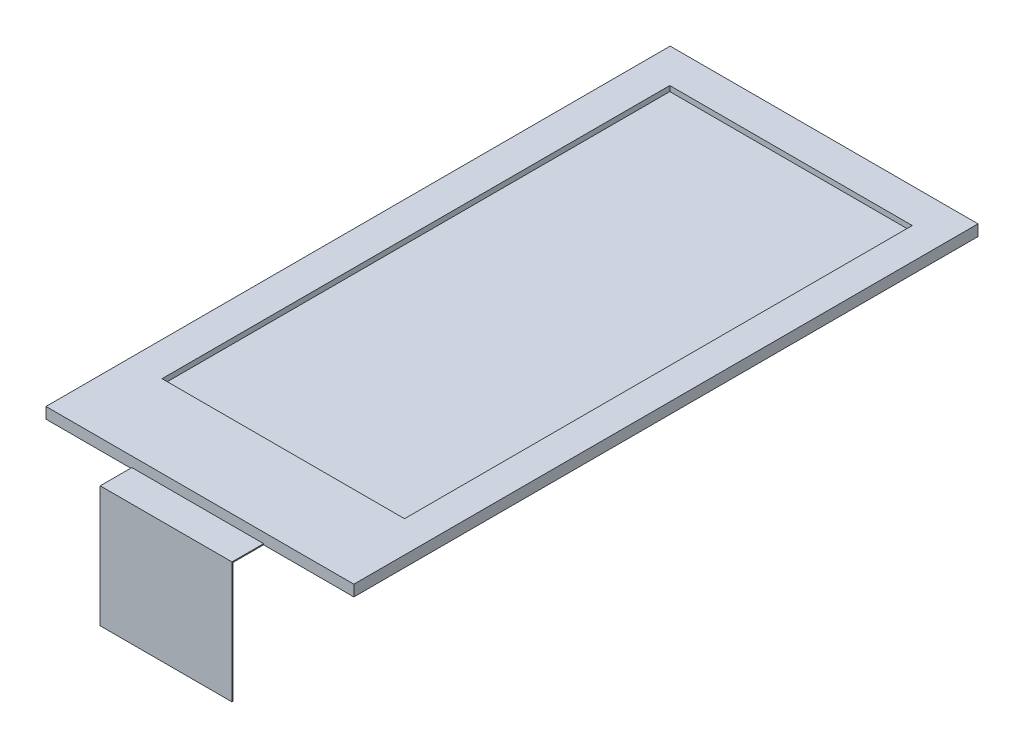
from build123d import *

# Parameters (mm, degrees)
BOSS_EXTRUDE1_DEPTH = 1.5
SKETCH2_W           = 29.2
SKETCH2_H           = 59.2
BOSS_EXTRUDE2_DEPTH = 1.05
SKETCH3_W           = 12.5
SKETCH3_H           = 14.3
BOSS_EXTRUDE3_DEPTH = 0.1
SKETCH4_W           = 12.5
SKETCH4_H           = 3.5
BOSS_EXTRUDE4_DEPTH = 0.2
SKETCH5_W           = 12.5
SKETCH5_H           = 11.4
BOSS_EXTRUDE5_DEPTH = 0.1
SKETCH6_W           = 12.5
SKETCH6_H           = 0.3
CUT_EXTRUDE1_DEPTH  = 11.3
CUT_EXTRUDE2_DEPTH  = 1.5
SKETCH10_W          = 23.000919901
SKETCH10_H          = 48.161967413
CUT_EXTRUDE3_DEPTH  = 0.5


with BuildPart() as part:
    # Sketch1 → Boss-Extrude1 (new body)
    with BuildSketch(Plane(origin=(0, 0, 0), x_dir=(1, 0, 0), z_dir=(0, 1, 0))):
        with BuildLine():
            Line((3.25, 0), (26.95, 0))
            ThreePointArc((26.95, 0), (29.248097039, -0.951902961), (30.2, -3.25))
            Line((30.2, -3.25), (30.2, -61.75))
            ThreePointArc((30.2, -61.75), (29.248097039, -64.048097039), (26.95, -65))
            Line((26.95, -65), (3.25, -65))
            ThreePointArc((3.25, -65), (0.951902961, -64.048097039), (0, -61.75))
            Line((0, -61.75), (0, -3.25))
            ThreePointArc((0, -3.25), (0.951902961, -0.951902961), (3.25, 0))
        make_face()
    extrude(amount=BOSS_EXTRUDE1_DEPTH)

    # Sketch2 → Boss-Extrude2 (add)
    with BuildSketch(Plane(origin=(0, 1.5, 0), x_dir=(1, 0, 0), z_dir=(0, 1, 0))):
        with Locations((15.1, -32.5)):
            Rectangle(SKETCH2_W, SKETCH2_H)
    extrude(amount=BOSS_EXTRUDE2_DEPTH)

    # Sketch3 → Boss-Extrude3 (add)
    with BuildSketch(Plane(origin=(0, 1.5, 0), x_dir=(1, 0, 0), z_dir=(0, 1, 0))):
        with Locations((14.89, -69.25)):
            Rectangle(SKETCH3_W, SKETCH3_H)
    extrude(amount=BOSS_EXTRUDE3_DEPTH)

    # Sketch4 → Boss-Extrude4 (add)
    with BuildSketch(Plane(origin=(0, 1.6, 0), x_dir=(1, 0, 0), z_dir=(0, 1, 0))):
        with Locations((14.89, -74.65)):
            Rectangle(SKETCH4_W, SKETCH4_H)
    extrude(amount=BOSS_EXTRUDE4_DEPTH)

    # Sketch5 → Boss-Extrude5 (add)
    with BuildSketch(Plane.XY.offset(65)):
        with Locations((14.89, -4.2)):
            Rectangle(SKETCH5_W, SKETCH5_H)
    extrude(amount=BOSS_EXTRUDE5_DEPTH)

    # Sketch6 → Cut-Extrude1 (cut)
    with BuildSketch(Plane.XY.offset(76.4)):
        with Locations((14.89, 1.65)):
            Rectangle(SKETCH6_W, SKETCH6_H)
    extrude(amount=-CUT_EXTRUDE1_DEPTH, mode=Mode.SUBTRACT)

    # Sketch8 → Cut-Extrude2 (cut)
    with BuildSketch(Plane.XZ):
        with BuildLine():
            Line((21.14, 65), (8.64, 65))
            Line((8.64, 65), (3.25, 65))
            ThreePointArc((3.25, 65), (0.951902961, 64.048097039), (0, 61.75))
            Line((0, 61.75), (0, 3.25))
            ThreePointArc((0, 3.25), (0.951902961, 0.951902961), (3.25, 0))
            Line((3.25, 0), (26.95, 0))
            ThreePointArc((26.95, 0), (29.248097039, 0.951902961), (30.2, 3.25))
            Line((30.2, 3.25), (30.2, 61.75))
            ThreePointArc((30.2, 61.75), (29.248097039, 64.048097039), (26.95, 65))
            Line((26.95, 65), (21.14, 65))
        make_face()
    extrude(amount=-CUT_EXTRUDE2_DEPTH, mode=Mode.SUBTRACT)

    # Sketch10 → Cut-Extrude3 (cut)
    with BuildSketch(Plane(origin=(0, 2.55, 0), x_dir=(1, 0, 0), z_dir=(0, 1, 0))):
        with Locations((15.222162275, -30.236639689)):
            Rectangle(SKETCH10_W, SKETCH10_H)
    extrude(amount=-CUT_EXTRUDE3_DEPTH, mode=Mode.SUBTRACT)


solid = part.part
